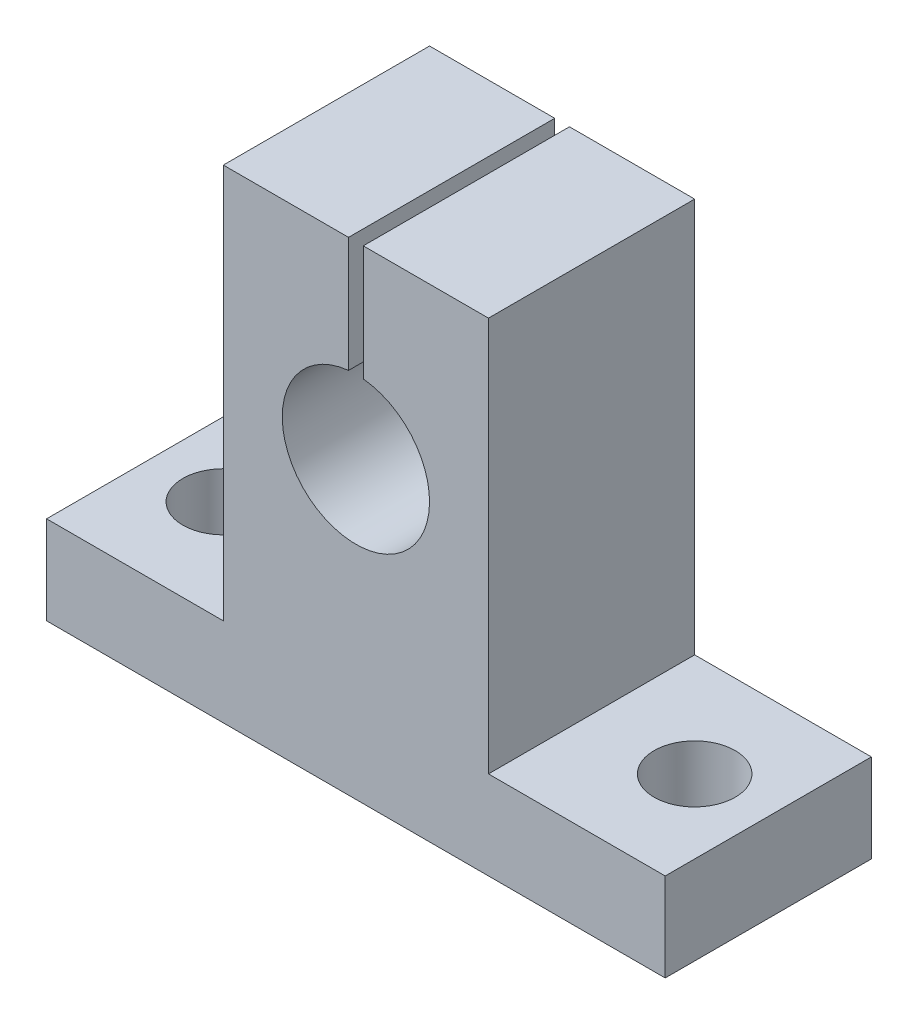
from build123d import *

# Parameters (mm, degrees)
SKETCH1_R           = 5
BOSS_EXTRUDE1_DEPTH = 14
SKETCH2_W           = 1
SKETCH2_H           = 15.34768378
CUT_EXTRUDE1_DEPTH  = 15
SKETCH3_R           = 2.75
CUT_EXTRUDE2_DEPTH  = 7


with BuildPart() as part:
    # Sketch1 → Boss-Extrude1 (new body)
    with BuildSketch(Plane.XY):
        Polygon((9, 12.8), (-9, 12.8), (-9, -14), (-21, -14), (-21, -20), (21, -20), (21, -14), (9, -14), align=None)
        Circle(SKETCH1_R, mode=Mode.SUBTRACT)
    extrude(amount=BOSS_EXTRUDE1_DEPTH)

    # Sketch2 → Cut-Extrude1 (cut, through all)
    with BuildSketch(Plane.XY.offset(14)):
        with Locations((0, 7.003057882)):
            Rectangle(SKETCH2_W, SKETCH2_H)
    extrude(amount=-CUT_EXTRUDE1_DEPTH, mode=Mode.SUBTRACT)

    # Sketch3 → Cut-Extrude2 (cut, through all)
    with BuildSketch(Plane(origin=(0, -14, 0), x_dir=(1, 0, 0), z_dir=(0, 1, 0))):
        with Locations((-16, -7)):
            Circle(SKETCH3_R)
        with Locations((16, -7)):
            Circle(SKETCH3_R)
    extrude(amount=-CUT_EXTRUDE2_DEPTH, mode=Mode.SUBTRACT)


solid = part.part
